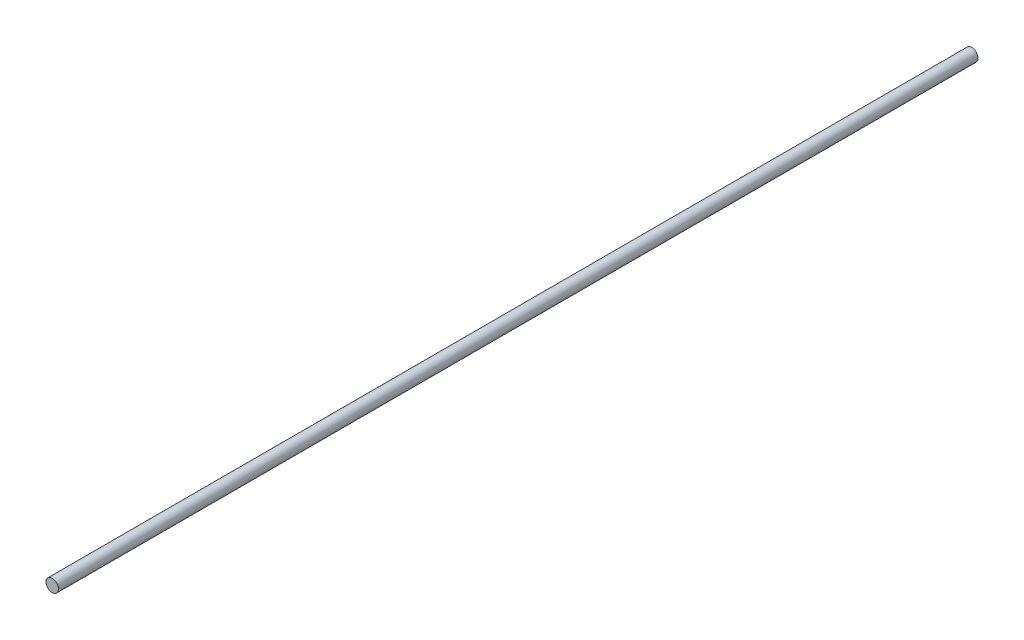
from build123d import *

# Parameters (mm, degrees)
ESQUISSE1_R        = 4
BOSS_EXTRU_1_DEPTH = 590


with BuildPart() as part:
    # Esquisse1 → Boss.-Extru.1 (new body)
    with BuildSketch(Plane.XY):
        Circle(ESQUISSE1_R)
    extrude(amount=BOSS_EXTRU_1_DEPTH)


solid = part.part
